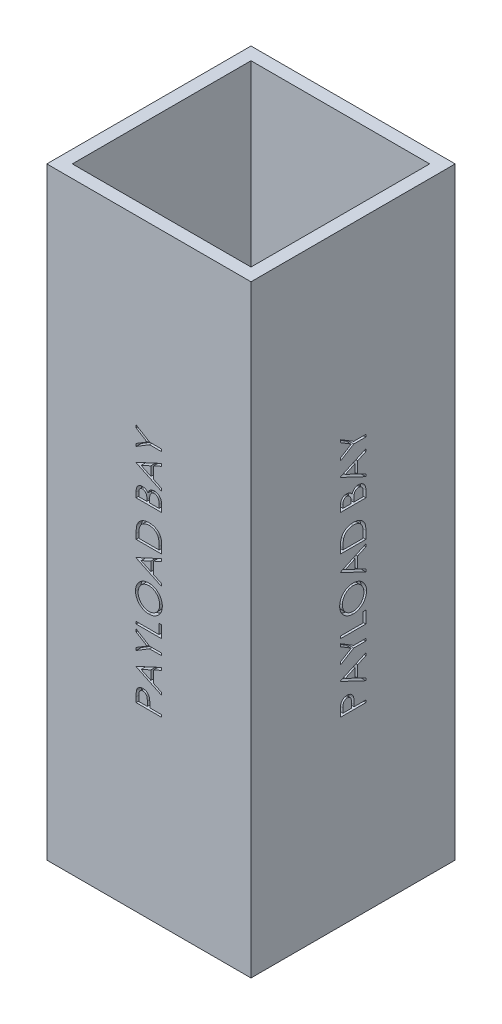
from build123d import *

# Parameters (mm, degrees)
SKETCH1_W           = 101.6
SKETCH1_H           = 101.6
SKETCH1_W_2         = 88.9
SKETCH1_H_2         = 88.9
BOSS_EXTRUDE1_DEPTH = 300
CUT_EXTRUDE1_DEPTH  = 2.54
CIRPATTERN1_COUNT   = 4


with BuildPart() as part:
    # Sketch1 → Boss-Extrude1 (new body)
    with BuildSketch(Plane(origin=(0, 0, 0), x_dir=(1, 0, 0), z_dir=(0, 1, 0))):
        Rectangle(SKETCH1_W, SKETCH1_H)
        Rectangle(SKETCH1_W_2, SKETCH1_H_2, mode=Mode.SUBTRACT)
    extrude(amount=BOSS_EXTRUDE1_DEPTH)

    # Sketch6 → Cut-Extrude1 (cut)
    with BuildSketch(Plane.ZY.offset(50.8)):
        with BuildLine():
            Line((-6.35, 90.082051282), (-6.35, 92.572696314))
            add(Edge.make_bspline(
                [(-6.35, 92.572696314), (-6.349811691, 92.744004459), (-6.349450882, 93.072238473), (-6.338511661, 93.542918818), (-6.323900522, 93.970399844), (-6.303646223, 94.353759798), (-6.279710024, 94.694178211), (-6.246138339, 94.990114698), (-6.211085266, 95.243895374), (-6.175447591, 95.395955919), (-6.159194712, 95.465304487)],
                knots=[0, 0, 0, 0, 0.000513909, 0.000984672, 0.001412348, 0.001797041, 0.002136358, 0.002435846, 0.002690583, 0.002904164, 0.002904164, 0.002904164, 0.002904164], degree=3))
            add(Edge.make_bspline(
                [(-6.159194712, 95.465304487), (-6.135165553, 95.553091687), (-6.087673454, 95.726597491), (-5.99256869, 95.976620926), (-5.879734333, 96.214446609), (-5.751382729, 96.441136022), (-5.601195819, 96.652560376), (-5.439164902, 96.855767619), (-5.254818851, 97.043584549), (-5.053971996, 97.218555122), (-4.839171698, 97.380275569), (-4.60651531, 97.516149986), (-4.36294889, 97.634954344), (-4.105162168, 97.732225501), (-3.832904869, 97.804560375), (-3.548111823, 97.858261731), (-3.250462794, 97.892503698), (-3.047042823, 97.895772087), (-2.943489583, 97.897435897)],
                knots=[0, 0, 0, 0, 0.000272928, 0.000539425, 0.000801167, 0.00106213, 0.001319735, 0.001578393, 0.001841062, 0.00210791, 0.002377077, 0.00264628, 0.002914809, 0.003189345, 0.003471382, 0.003758783, 0.004058271, 0.004368814, 0.004368814, 0.004368814, 0.004368814], degree=3))
            add(Edge.make_bspline(
                [(-2.943489583, 97.897435897), (-2.839067365, 97.895906728), (-2.634758241, 97.892914804), (-2.335862696, 97.857005426), (-2.050227394, 97.808635873), (-1.778485674, 97.734260855), (-1.522251307, 97.636849412), (-1.277608551, 97.522578249), (-1.048719455, 97.384752296), (-0.834753057, 97.226383914), (-0.635508519, 97.050210986), (-0.452429693, 96.856978896), (-0.286588236, 96.647467749), (-0.137612361, 96.422343383), (-0.008956718, 96.179411074), (0.106276931, 95.92235526), (0.20305478, 95.648941618), (0.25396386, 95.459738781), (0.279847756, 95.363541667)],
                knots=[0, 0, 0, 0, 0.000313086, 0.000612574, 0.000902017, 0.001181599, 0.001456135, 0.001723565, 0.001990583, 0.002256192, 0.00252113, 0.002787469, 0.003053674, 0.003321805, 0.003596116, 0.003877417, 0.00416629, 0.004465075, 0.004465075, 0.004465075, 0.004465075], degree=3))
            add(Edge.make_bspline(
                [(0.279847756, 95.363541667), (0.296755106, 95.283975863), (0.333808547, 95.109602778), (0.375455577, 94.822445764), (0.409610691, 94.48794002), (0.441484518, 94.107223684), (0.458373661, 93.679408932), (0.47820427, 93.205476968), (0.487561251, 92.683823846), (0.488152728, 92.319987058), (0.488461538, 92.130028045)],
                knots=[0, 0, 0, 0, 0.000243979, 0.000534694, 0.000869865, 0.001252695, 0.001680583, 0.002154115, 0.002675749, 0.003245626, 0.003245626, 0.003245626, 0.003245626], degree=3))
            Line((0.488461538, 92.130028045), (0.488461538, 91.221794872))
            Line((0.488461538, 91.221794872), (6.35, 91.221794872))
            Line((6.35, 91.221794872), (6.35, 90.082051282))
            Line((6.35, 90.082051282), (-6.35, 90.082051282))
        make_face()
        with BuildLine():
            Line((-5.047435897, 91.221794872), (-0.814102564, 91.221794872))
            Line((-0.814102564, 91.221794872), (-0.786117788, 93.4453125))
            add(Edge.make_bspline(
                [(-0.786117788, 93.4453125), (-0.786058006, 93.553879847), (-0.785942597, 93.763466872), (-0.800452377, 94.066211014), (-0.816979073, 94.347130601), (-0.841974741, 94.605169257), (-0.874740105, 94.84123239), (-0.915487111, 95.053280991), (-0.959785588, 95.244486591), (-1.033797354, 95.464431594), (-1.147598039, 95.711657023), (-1.313260324, 95.981731934), (-1.527867901, 96.208844847), (-1.768488369, 96.40501689), (-2.035447832, 96.563756171), (-2.322580965, 96.675740401), (-2.62563392, 96.744695668), (-2.832880378, 96.75330752), (-2.938401442, 96.757692308)],
                knots=[0, 0, 0, 0, 0.000325651, 0.000628662, 0.000909076, 0.001169816, 0.001406195, 0.001623739, 0.00181749, 0.001994481, 0.002318937, 0.002632302, 0.002940177, 0.003251283, 0.003561503, 0.003867638, 0.004172555, 0.00448885, 0.00448885, 0.00448885, 0.00448885], degree=3))
            add(Edge.make_bspline(
                [(-2.938401442, 96.757692308), (-3.040503948, 96.753110659), (-3.243471094, 96.744002909), (-3.540938354, 96.676309447), (-3.824816581, 96.562553668), (-4.089626181, 96.404878111), (-4.329717186, 96.21346686), (-4.538638533, 95.991169219), (-4.705467251, 95.737416482), (-4.81729303, 95.503335586), (-4.882763075, 95.293719024), (-4.930049703, 95.112545142), (-4.962657093, 94.906933975), (-4.993858298, 94.678839141), (-5.019043897, 94.428550238), (-5.036533738, 94.154476492), (-5.046662216, 93.857530593), (-5.04717176, 93.651390347), (-5.047435897, 93.54453125)],
                knots=[0, 0, 0, 0, 0.000306146, 0.00060858, 0.000909985, 0.001220206, 0.001529716, 0.001828533, 0.002131234, 0.002437391, 0.002603127, 0.00278947, 0.002998595, 0.003227067, 0.003480211, 0.003753009, 0.004050839, 0.004371402, 0.004371402, 0.004371402, 0.004371402], degree=3))
            Line((-5.047435897, 93.54453125), (-5.047435897, 91.221794872))
        make_face(mode=Mode.SUBTRACT)
        Polygon((-6.35, 105.712820513), (6.35, 111.574358974), (6.35, 110.335396635), (2.279487179, 108.457872596), (2.279487179, 102.700641026), (6.35, 100.769691506), (6.35, 99.525641026), (-6.35, 105.55), align=None)
        Polygon((-3.874619391, 105.618689904), (0.976923077, 103.31885016), (0.976923077, 107.857471955), align=None, mode=Mode.SUBTRACT)
        Polygon((-6.35, 112.551282051), (-6.35, 113.856390224), (-0.89296875, 117.194210737), (-6.35, 120.526943109), (-6.35, 121.832051282), (0.312920673, 117.761538462), (6.35, 117.761538462), (6.35, 116.621794872), (0.312920673, 116.621794872), align=None)
        Polygon((-6.35, 123.948717949), (-6.35, 125.088461538), (5.047435897, 125.088461538), (5.047435897, 129.973076923), (6.35, 129.973076923), (6.35, 123.948717949), align=None)
        with BuildLine():
            add(Edge.make_bspline(
                [(-6.675641026, 138.032692308), (-6.669785071, 138.267878789), (-6.658283492, 138.729804442), (-6.567334124, 139.408062537), (-6.41764098, 140.057525074), (-6.206242297, 140.678565423), (-5.932190469, 141.268821615), (-5.599295982, 141.829960687), (-5.205535771, 142.360300963), (-4.756691829, 142.856191897), (-4.26513446, 143.308559312), (-3.738912975, 143.705514067), (-3.184643364, 144.040382863), (-2.60229672, 144.314509446), (-1.99323266, 144.529716981), (-1.354037691, 144.678184212), (-0.688898346, 144.77303121), (-0.235229152, 144.784118924), (-0.005088141, 144.78974359)],
                knots=[0, 0, 0, 0, 0.000705368, 0.001385402, 0.0020488, 0.002702076, 0.003349741, 0.00399766, 0.004656078, 0.005327949, 0.006001364, 0.006657226, 0.007302086, 0.007940532, 0.008585026, 0.009236039, 0.009906328, 0.010596447, 0.010596447, 0.010596447, 0.010596447], degree=3))
            add(Edge.make_bspline(
                [(-0.005088141, 144.78974359), (0.223356266, 144.784117031), (0.673646657, 144.773026431), (1.334584132, 144.678107253), (1.969850898, 144.529054513), (2.578031024, 144.317174008), (3.159194899, 144.042837073), (3.71388411, 143.707475299), (4.241511135, 143.311273919), (4.736454933, 142.860827488), (5.189213913, 142.368333696), (5.588564969, 141.844134632), (5.923579539, 141.2898798), (6.200766497, 140.711312922), (6.411489139, 140.103890905), (6.56490218, 139.472033968), (6.658807614, 138.812299547), (6.669968316, 138.362882653), (6.675641026, 138.134455128)],
                knots=[0, 0, 0, 0, 0.000685036, 0.001350284, 0.001998823, 0.002640075, 0.00327852, 0.003923381, 0.004581277, 0.005254856, 0.005928271, 0.006585666, 0.00722835, 0.007867883, 0.008506734, 0.009153393, 0.009816123, 0.010501158, 0.010501158, 0.010501158, 0.010501158], degree=3))
            add(Edge.make_bspline(
                [(6.675641026, 138.134455128), (6.670018965, 137.904315456), (6.658936386, 137.450648902), (6.563935289, 136.784671659), (6.415376844, 136.145035274), (6.203071175, 135.533568914), (5.928688652, 134.949931598), (5.594118477, 134.392981869), (5.19712685, 133.864955249), (4.746579565, 133.370229483), (4.256099934, 132.917568107), (3.730558494, 132.522926944), (3.180265837, 132.188281533), (2.603694821, 131.914820298), (2.003632729, 131.698323545), (1.376076825, 131.550623205), (0.724604903, 131.455061322), (0.281037815, 131.444049165), (0.055969551, 131.438461538)],
                knots=[0, 0, 0, 0, 0.000690119, 0.001360408, 0.002013897, 0.002657552, 0.003298299, 0.003945339, 0.004603236, 0.005276814, 0.005950229, 0.006602529, 0.007245213, 0.007879059, 0.008513962, 0.009155077, 0.009810248, 0.010485118, 0.010485118, 0.010485118, 0.010485118], degree=3))
            add(Edge.make_bspline(
                [(0.055969551, 131.438461538), (-0.095097562, 131.440401502), (-0.395326011, 131.444256954), (-0.841156245, 131.490672524), (-1.279816632, 131.558024983), (-1.710059786, 131.654551923), (-2.130832502, 131.780795971), (-2.545036699, 131.929756185), (-2.948474782, 132.111692195), (-3.343057946, 132.317361975), (-3.722635205, 132.546911965), (-4.081426835, 132.800461113), (-4.422443595, 133.069103735), (-4.736848437, 133.363610906), (-5.033787705, 133.674276293), (-5.308698135, 134.006139551), (-5.564058671, 134.357175695), (-5.794183909, 134.728895187), (-6.002315626, 135.112138642), (-6.180920628, 135.507205807), (-6.33421348, 135.908731081), (-6.45845876, 136.318595089), (-6.556546433, 136.735709433), (-6.623338831, 137.16098448), (-6.669872784, 137.594081427), (-6.673710006, 137.885859641), (-6.675641026, 138.032692308)],
                knots=[0, 0, 0, 0, 0.000453023, 0.000900331, 0.00134327, 0.001783953, 0.002221843, 0.002660465, 0.003103469, 0.003548398, 0.003994743, 0.004433047, 0.004865726, 0.005295975, 0.005724256, 0.006154227, 0.006587795, 0.007025471, 0.007464852, 0.007895214, 0.008325184, 0.00875333, 0.009179133, 0.00960951, 0.010044159, 0.010484467, 0.010484467, 0.010484467, 0.010484467], degree=3))
        make_face()
        with BuildLine():
            add(Edge.make_bspline(
                [(-5.373076923, 138.088661859), (-5.371612874, 137.968138647), (-5.368698771, 137.728244435), (-5.330103131, 137.371634762), (-5.275488499, 137.019606801), (-5.196168901, 136.672841773), (-5.093572448, 136.330612447), (-4.969833028, 135.992766886), (-4.820275395, 135.660463451), (-4.652079665, 135.334117284), (-4.461036223, 135.021265912), (-4.258166746, 134.721155899), (-4.035933534, 134.441593359), (-3.799142721, 134.178737887), (-3.545739327, 133.933243177), (-3.277387483, 133.705217516), (-2.992926494, 133.494847893), (-2.693527038, 133.304666015), (-2.380860728, 133.135418989), (-2.060904396, 132.983885031), (-1.729897889, 132.858269162), (-1.389906788, 132.758762678), (-1.042429358, 132.674304473), (-0.685572416, 132.621326036), (-0.320566176, 132.582350109), (-0.073887757, 132.579597426), (0.05088141, 132.578205128)],
                knots=[0, 0, 0, 0, 0.000361401, 0.000719348, 0.001074863, 0.001429731, 0.001785501, 0.002146095, 0.002508248, 0.002878058, 0.003246738, 0.003607323, 0.00396412, 0.004317168, 0.004668001, 0.005021764, 0.005372855, 0.005728561, 0.006084895, 0.00643885, 0.006789913, 0.007145683, 0.007501125, 0.007861666, 0.008227207, 0.008601324, 0.008601324, 0.008601324, 0.008601324], degree=3))
            add(Edge.make_bspline(
                [(0.05088141, 132.578205128), (0.234345869, 132.58284164), (0.595277215, 132.591963092), (1.124266852, 132.671486696), (1.63314324, 132.794954947), (2.118873279, 132.973960588), (2.583622971, 133.202317606), (3.025583679, 133.480866807), (3.444625029, 133.812159116), (3.837627676, 134.188256745), (4.19619396, 134.599509589), (4.511375607, 135.035990281), (4.776641272, 135.494245547), (4.998397407, 135.971634123), (5.165459253, 136.47223187), (5.284574271, 136.992829147), (5.361776101, 137.533437463), (5.369274234, 137.901830698), (5.373076923, 138.088661859)],
                knots=[0, 0, 0, 0, 0.000550108, 0.001082232, 0.001601154, 0.002118677, 0.00263181, 0.003152009, 0.003682843, 0.004231661, 0.004781633, 0.005317521, 0.005844193, 0.006367833, 0.006893982, 0.007424089, 0.007968455, 0.008528619, 0.008528619, 0.008528619, 0.008528619], degree=3))
            add(Edge.make_bspline(
                [(5.373076923, 138.088661859), (5.371352914, 138.214245402), (5.367933685, 138.463315285), (5.333446658, 138.833768939), (5.278253288, 139.197582943), (5.198393676, 139.554085094), (5.099767851, 139.903742487), (4.97743268, 140.245500082), (4.830782133, 140.579244366), (4.667344949, 140.906616436), (4.481684714, 141.220286113), (4.281550104, 141.518575726), (4.063238117, 141.797656623), (3.829627504, 142.060388767), (3.57700307, 142.304162974), (3.310282099, 142.5315394), (3.025217373, 142.738271673), (2.727044186, 142.927808831), (2.416657403, 143.099120929), (2.095821442, 143.246271725), (1.766257055, 143.371941549), (1.427722103, 143.473245665), (1.080978091, 143.552668472), (0.725528754, 143.607384366), (0.362093818, 143.645660851), (0.116280345, 143.648545747), (-0.007632212, 143.65)],
                knots=[0, 0, 0, 0, 0.00037666, 0.00074703, 0.001115112, 0.001479909, 0.001842294, 0.002204411, 0.002567866, 0.002935359, 0.003301431, 0.003660587, 0.004012239, 0.004363588, 0.004714421, 0.005064598, 0.005414184, 0.00576989, 0.006123991, 0.006476875, 0.006827938, 0.007181271, 0.007536139, 0.007894167, 0.008259708, 0.008631282, 0.008631282, 0.008631282, 0.008631282], degree=3))
            add(Edge.make_bspline(
                [(-0.007632212, 143.65), (-0.130697041, 143.648544533), (-0.374818801, 143.645657346), (-0.735719484, 143.607403224), (-1.088609709, 143.552608564), (-1.432104078, 143.473641023), (-1.766290161, 143.37185904), (-2.090854054, 143.246356428), (-2.407005009, 143.098364107), (-2.713961172, 142.928516926), (-3.008510573, 142.737597379), (-3.290092515, 142.528972715), (-3.553442649, 142.299057084), (-3.804973342, 142.05435931), (-4.03965346, 141.788996329), (-4.256576238, 141.502921828), (-4.465515493, 141.203258692), (-4.650429047, 140.883230258), (-4.822051388, 140.554134185), (-4.968471586, 140.216134055), (-5.094225799, 139.874057007), (-5.196475173, 139.526535353), (-5.275184667, 139.173733358), (-5.330152005, 138.815856192), (-5.368685515, 138.454153049), (-5.371608475, 138.210878865), (-5.373076923, 138.088661859)],
                knots=[0, 0, 0, 0, 0.000369031, 0.00073204, 0.001087555, 0.001439943, 0.001788407, 0.002134718, 0.002482986, 0.00283486, 0.003186283, 0.003535331, 0.003885231, 0.004234241, 0.004587492, 0.004946738, 0.00531086, 0.005682608, 0.006054677, 0.006423813, 0.006786796, 0.007147444, 0.007509758, 0.007870298, 0.008233308, 0.008599795, 0.008599795, 0.008599795, 0.008599795], degree=3))
        make_face(mode=Mode.SUBTRACT)
        Polygon((-6.35, 152.605128205), (6.35, 158.466666667), (6.35, 157.227704327), (2.279487179, 155.350180288), (2.279487179, 149.592948718), (6.35, 147.661999199), (6.35, 146.417948718), (-6.35, 152.442307692), align=None)
        Polygon((-3.874619391, 152.510997596), (0.976923077, 150.211157853), (0.976923077, 154.749779647), align=None, mode=Mode.SUBTRACT)
        with BuildLine():
            Line((6.35, 160.420512821), (-6.35, 160.420512821))
            Line((-6.35, 160.420512821), (-6.35, 162.984935897))
            add(Edge.make_bspline(
                [(-6.35, 162.984935897), (-6.348394103, 163.207980512), (-6.345291519, 163.638901546), (-6.325619614, 164.26160957), (-6.290819923, 164.837767793), (-6.2401305, 165.365481311), (-6.177889492, 165.846198851), (-6.099873739, 166.278574372), (-6.00775095, 166.664843576), (-5.929208887, 166.902404118), (-5.892067308, 167.01474359)],
                knots=[0, 0, 0, 0, 0.000669134, 0.001292764, 0.001868826, 0.002400433, 0.002882928, 0.003322552, 0.003718071, 0.004072903, 0.004072903, 0.004072903, 0.004072903], degree=3))
            add(Edge.make_bspline(
                [(-5.892067308, 167.01474359), (-5.836093327, 167.161694877), (-5.725414669, 167.452265085), (-5.51631439, 167.865755961), (-5.280367806, 168.256337905), (-5.012145128, 168.620896847), (-4.715148895, 168.96034751), (-4.391500844, 169.278542555), (-4.034011275, 169.56763688), (-3.649043287, 169.832133132), (-3.241529407, 170.070675187), (-2.812137035, 170.27800451), (-2.363076518, 170.450195854), (-1.895588611, 170.593136678), (-1.408647571, 170.705791053), (-0.9016858, 170.782651182), (-0.376707035, 170.833345923), (-0.02047398, 170.838440622), (0.160276442, 170.841025641)],
                knots=[0, 0, 0, 0, 0.000471477, 0.000932263, 0.001387773, 0.001839114, 0.00228809, 0.002739654, 0.00319897, 0.003665423, 0.00413972, 0.004614208, 0.005094222, 0.005581098, 0.006079742, 0.006592118, 0.007118421, 0.007660523, 0.007660523, 0.007660523, 0.007660523], degree=3))
            add(Edge.make_bspline(
                [(0.160276442, 170.841025641), (0.317252935, 170.838743386), (0.626591509, 170.834245964), (1.082488494, 170.793862471), (1.52486052, 170.735165446), (1.951601475, 170.644291121), (2.366448593, 170.533972212), (2.764986355, 170.392592467), (3.150849201, 170.230613026), (3.518898525, 170.041806471), (3.867366737, 169.834246367), (4.196106488, 169.612889743), (4.497822934, 169.372716402), (4.780422415, 169.120834747), (5.036355603, 168.851170688), (5.270287817, 168.567007346), (5.478302523, 168.267240384), (5.663668473, 167.950014161), (5.829436114, 167.61109204), (5.967706215, 167.239813205), (6.087462238, 166.837936329), (6.182728161, 166.40316961), (6.259560811, 165.937063728), (6.310716285, 165.438325694), (6.345409359, 164.907898054), (6.348440074, 164.543663461), (6.35, 164.356189904)],
                knots=[0, 0, 0, 0, 0.000470825, 0.00092781, 0.001372149, 0.001808729, 0.0022358, 0.002659019, 0.003076254, 0.003490407, 0.003898792, 0.004292531, 0.004678333, 0.00505483, 0.005427317, 0.005792478, 0.006158046, 0.006520636, 0.006893843, 0.007288379, 0.00770775, 0.008150915, 0.008622694, 0.009124186, 0.009654385, 0.010216717, 0.010216717, 0.010216717, 0.010216717], degree=3))
            Line((6.35, 164.356189904), (6.35, 160.420512821))
        make_face()
        with BuildLine():
            Line((5.047435897, 161.56025641), (5.047435897, 163.018008814))
            add(Edge.make_bspline(
                [(5.047435897, 163.018008814), (5.046535662, 163.227480331), (5.04480418, 163.630370771), (5.029610614, 164.209701218), (5.004784155, 164.739035028), (4.970040301, 165.218447362), (4.924071326, 165.647667536), (4.872818108, 166.027592571), (4.808964501, 166.35697708), (4.751085305, 166.556292466), (4.724338942, 166.648397436)],
                knots=[0, 0, 0, 0, 0.000628406, 0.001208655, 0.001738433, 0.002218042, 0.002650422, 0.003033235, 0.00336802, 0.003655635, 0.003655635, 0.003655635, 0.003655635], degree=3))
            add(Edge.make_bspline(
                [(4.724338942, 166.648397436), (4.683511867, 166.764324362), (4.602832871, 166.993409301), (4.45566639, 167.323177636), (4.281342714, 167.630725124), (4.087567265, 167.921407724), (3.867514454, 168.191116069), (3.625936061, 168.442993512), (3.36172837, 168.676731682), (3.075319806, 168.888730377), (2.769816125, 169.080752404), (2.444677018, 169.245595261), (2.104473453, 169.389151793), (1.746451287, 169.502822569), (1.373234633, 169.592446996), (0.9828882, 169.655268709), (0.575757403, 169.694269377), (0.298593328, 169.698919006), (0.157732372, 169.701282051)],
                knots=[0, 0, 0, 0, 0.000368636, 0.000728467, 0.00108158, 0.001428031, 0.001775294, 0.002124361, 0.00247402, 0.002832229, 0.003192239, 0.003555195, 0.003924673, 0.00429879, 0.004680748, 0.005075153, 0.005483989, 0.005906496, 0.005906496, 0.005906496, 0.005906496], degree=3))
            add(Edge.make_bspline(
                [(0.157732372, 169.701282051), (0.009202315, 169.699419551), (-0.282586297, 169.695760654), (-0.710723963, 169.649771013), (-1.122496609, 169.582564226), (-1.517931775, 169.485377708), (-1.897800939, 169.361531376), (-2.260003161, 169.206973676), (-2.608363686, 169.030383372), (-2.934842098, 168.820276978), (-3.243608523, 168.590168968), (-3.526473502, 168.334797806), (-3.784081392, 168.058220695), (-4.020444041, 167.763454241), (-4.226052236, 167.442191052), (-4.409972479, 167.101999089), (-4.566058713, 166.737887653), (-4.649076301, 166.4845673), (-4.691266026, 166.355829327)],
                knots=[0, 0, 0, 0, 0.000445394, 0.00087498, 0.001290296, 0.001696304, 0.002095342, 0.002487525, 0.00287666, 0.003265537, 0.003650709, 0.004030799, 0.004406986, 0.004783646, 0.005162584, 0.005549584, 0.005942765, 0.00634906, 0.00634906, 0.00634906, 0.00634906], degree=3))
            add(Edge.make_bspline(
                [(-4.691266026, 166.355829327), (-4.720717064, 166.249326596), (-4.783338052, 166.022872568), (-4.851647261, 165.653340799), (-4.911897871, 165.237451542), (-4.962908471, 164.773358341), (-4.999511037, 164.261590218), (-5.026984093, 163.701753579), (-5.045513874, 163.093606442), (-5.046779183, 162.672029819), (-5.047435897, 162.45322516)],
                knots=[0, 0, 0, 0, 0.000331365, 0.000704572, 0.001126244, 0.001592052, 0.002104832, 0.002665226, 0.00327352, 0.00392991, 0.00392991, 0.00392991, 0.00392991], degree=3))
            Line((-5.047435897, 162.45322516), (-5.047435897, 161.56025641))
            Line((-5.047435897, 161.56025641), (5.047435897, 161.56025641))
        make_face(mode=Mode.SUBTRACT)
        with BuildLine():
            Line((-6.35, 178.330769231), (-6.35, 180.80869391))
            add(Edge.make_bspline(
                [(-6.35, 180.80869391), (-6.349372317, 180.929993444), (-6.34815571, 181.165102129), (-6.32884905, 181.506958107), (-6.303182672, 181.827265278), (-6.260128703, 182.125457622), (-6.215487417, 182.40347543), (-6.149964695, 182.658496238), (-6.077592462, 182.892656163), (-5.966237959, 183.173834305), (-5.793303013, 183.492869434), (-5.536824054, 183.835772502), (-5.229326494, 184.133844772), (-4.878908769, 184.387294554), (-4.493409562, 184.590693397), (-4.081123013, 184.735981885), (-3.64898535, 184.829320743), (-3.352715027, 184.838799389), (-3.202984776, 184.843589744)],
                knots=[0, 0, 0, 0, 0.000363838, 0.000705208, 0.00102698, 0.001327407, 0.001608892, 0.001871129, 0.002116536, 0.002343771, 0.002777466, 0.0032008, 0.003623583, 0.004057151, 0.004494139, 0.004926249, 0.005365321, 0.005813951, 0.005813951, 0.005813951, 0.005813951], degree=3))
            add(Edge.make_bspline(
                [(-3.202984776, 184.843589744), (-3.062737383, 184.839599728), (-2.787138031, 184.83175897), (-2.384737295, 184.757696306), (-2.002077719, 184.640148273), (-1.639486801, 184.47769215), (-1.303714203, 184.268376526), (-0.995800058, 184.017586986), (-0.727381826, 183.716265358), (-0.577377362, 183.490393651), (-0.501181891, 183.375661058)],
                knots=[0, 0, 0, 0, 0.000420396, 0.000826117, 0.001222837, 0.001619092, 0.002014431, 0.002406622, 0.002806568, 0.003219445, 0.003219445, 0.003219445, 0.003219445], degree=3))
            add(Edge.make_bspline(
                [(-0.501181891, 183.375661058), (-0.445773816, 183.519920678), (-0.339764444, 183.795925067), (-0.152634166, 184.17596648), (0.051636421, 184.502202218), (0.271263785, 184.781005131), (0.511490195, 185.018194242), (0.774267381, 185.223613728), (1.059380217, 185.401202875), (1.365780824, 185.552330012), (1.690871704, 185.671042262), (2.030682193, 185.75829412), (2.383909628, 185.809905491), (2.623616838, 185.816946074), (2.745052083, 185.820512821)],
                knots=[0, 0, 0, 0, 0.000463447, 0.000886689, 0.001268545, 0.0016162, 0.001949007, 0.002278795, 0.002614805, 0.002954998, 0.003301897, 0.00365114, 0.00400589, 0.004370127, 0.004370127, 0.004370127, 0.004370127], degree=3))
            add(Edge.make_bspline(
                [(2.745052083, 185.820512821), (2.869029524, 185.81696904), (3.112958611, 185.809996552), (3.471291465, 185.758532445), (3.813764183, 185.671454355), (4.142434121, 185.551303705), (4.456612174, 185.395568463), (4.755160179, 185.203304589), (5.038699261, 184.977211083), (5.307729832, 184.721688874), (5.553901262, 184.436929363), (5.765525674, 184.123106054), (5.947492508, 183.788816177), (6.095643415, 183.429786154), (6.209941742, 183.046932515), (6.289576238, 182.640468299), (6.343323875, 182.211062893), (6.347736865, 181.916385354), (6.35, 181.765264423)],
                knots=[0, 0, 0, 0, 0.000371861, 0.000731647, 0.001083355, 0.001430255, 0.001779543, 0.002133105, 0.002493475, 0.002865962, 0.003244832, 0.003620227, 0.003999302, 0.004384828, 0.004783241, 0.005195859, 0.005626281, 0.006079382, 0.006079382, 0.006079382, 0.006079382], degree=3))
            Line((6.35, 181.765264423), (6.35, 178.330769231))
            Line((6.35, 178.330769231), (-6.35, 178.330769231))
        make_face()
        with BuildLine():
            Line((-5.047435897, 179.470512821), (-0.976923077, 179.470512821))
            Line((-0.976923077, 179.470512821), (-0.976923077, 180.236278045))
            add(Edge.make_bspline(
                [(-0.976923077, 180.236278045), (-0.978374226, 180.348215103), (-0.981178141, 180.564500309), (-0.989210049, 180.877718217), (-1.011700083, 181.168457579), (-1.034183694, 181.43621648), (-1.070739951, 181.680573468), (-1.114254566, 181.900986513), (-1.160274294, 182.100916987), (-1.238545357, 182.331469368), (-1.354184303, 182.593027832), (-1.533820739, 182.871677561), (-1.747610778, 183.118470549), (-1.996602328, 183.324374206), (-2.267797908, 183.494378417), (-2.558816675, 183.613471713), (-2.863802254, 183.692867668), (-3.073579537, 183.700149172), (-3.180088141, 183.703846154)],
                knots=[0, 0, 0, 0, 0.000335856, 0.000648942, 0.000939679, 0.001210548, 0.001454845, 0.001680365, 0.001884605, 0.002069641, 0.0024101, 0.002739663, 0.003060599, 0.003385683, 0.003705519, 0.004016874, 0.004326007, 0.004644839, 0.004644839, 0.004644839, 0.004644839], degree=3))
            add(Edge.make_bspline(
                [(-3.180088141, 183.703846154), (-3.250585181, 183.701969054), (-3.388872822, 183.698286917), (-3.591119209, 183.667034672), (-3.781156629, 183.61639774), (-3.960808966, 183.547821684), (-4.125611427, 183.454136614), (-4.283438701, 183.34554331), (-4.424837705, 183.211469459), (-4.556615938, 183.059954103), (-4.674557016, 182.886593511), (-4.77225292, 182.687652627), (-4.860797869, 182.468274376), (-4.926345062, 182.222506905), (-4.983983541, 181.955442602), (-5.020198184, 181.663465315), (-5.043502651, 181.348425244), (-5.046095572, 181.130142044), (-5.047435897, 181.017307692)],
                knots=[0, 0, 0, 0, 0.000211403, 0.00041469, 0.000612163, 0.000800665, 0.000989698, 0.001179568, 0.001373986, 0.00157239, 0.001781252, 0.00200084, 0.002236108, 0.002489814, 0.002762742, 0.003055266, 0.00337156, 0.003710008, 0.003710008, 0.003710008, 0.003710008], degree=3))
            Line((-5.047435897, 181.017307692), (-5.047435897, 179.470512821))
        make_face(mode=Mode.SUBTRACT)
        with BuildLine():
            Line((0.325641026, 179.470512821), (5.047435897, 179.470512821))
            Line((5.047435897, 179.470512821), (5.047435897, 181.093629808))
            add(Edge.make_bspline(
                [(5.047435897, 181.093629808), (5.045904986, 181.209800616), (5.042954355, 181.433704534), (5.036034513, 181.757237907), (5.009857802, 182.056320822), (4.985709904, 182.33189678), (4.944418036, 182.583234398), (4.905449249, 182.812266982), (4.847602867, 183.015234803), (4.768099821, 183.252754112), (4.640825315, 183.5182458), (4.454878463, 183.808380427), (4.225391341, 184.061373325), (3.964393202, 184.278544111), (3.681391572, 184.457762875), (3.380086158, 184.58636929), (3.066336778, 184.666289903), (2.852362575, 184.675933072), (2.745052083, 184.680769231)],
                knots=[0, 0, 0, 0, 0.000348575, 0.000671832, 0.000970368, 0.00124908, 0.001501302, 0.001734317, 0.001945399, 0.00213366, 0.002485313, 0.002825429, 0.003164106, 0.003505476, 0.003841486, 0.004165184, 0.004484806, 0.004806367, 0.004806367, 0.004806367, 0.004806367], degree=3))
            add(Edge.make_bspline(
                [(2.745052083, 184.680769231), (2.677946231, 184.679770435), (2.54481695, 184.677788953), (2.34920062, 184.647769991), (2.159617461, 184.604342067), (1.975277451, 184.547146241), (1.799280024, 184.467189559), (1.630950229, 184.369169369), (1.466897116, 184.256967846), (1.256812893, 184.083862119), (1.01776619, 183.828402227), (0.786615655, 183.465365211), (0.597190031, 183.054858428), (0.517108985, 182.756426067), (0.475741186, 182.602263622)],
                knots=[0, 0, 0, 0, 0.000201126, 0.000399009, 0.000592174, 0.000784466, 0.000976909, 0.00117066, 0.001368248, 0.001572487, 0.001986491, 0.00241129, 0.002858707, 0.003336803, 0.003336803, 0.003336803, 0.003336803], degree=3))
            add(Edge.make_bspline(
                [(0.475741186, 182.602263622), (0.463204167, 182.540472331), (0.436021324, 182.406496067), (0.407327657, 182.188028561), (0.381764154, 181.938615551), (0.362855097, 181.657681111), (0.343309639, 181.344869802), (0.33570843, 180.999513554), (0.326639687, 180.623022727), (0.325982428, 180.361793261), (0.325641026, 180.226101763)],
                knots=[0, 0, 0, 0, 0.000189102, 0.000410011, 0.000660625, 0.000941212, 0.001254639, 0.001600782, 0.001977382, 0.002384441, 0.002384441, 0.002384441, 0.002384441], degree=3))
            Line((0.325641026, 180.226101763), (0.325641026, 179.470512821))
        make_face(mode=Mode.SUBTRACT)
        Polygon((-6.35, 193.635897436), (6.35, 199.497435897), (6.35, 198.258473558), (2.279487179, 196.380949519), (2.279487179, 190.623717949), (6.35, 188.692768429), (6.35, 187.448717949), (-6.35, 193.473076923), align=None)
        Polygon((-3.874619391, 193.541766827), (0.976923077, 191.241927083), (0.976923077, 195.780548878), align=None, mode=Mode.SUBTRACT)
        Polygon((-6.35, 200.474358974), (-6.35, 201.779467147), (-0.89296875, 205.11728766), (-6.35, 208.450020032), (-6.35, 209.755128205), (0.312920673, 205.684615385), (6.35, 205.684615385), (6.35, 204.544871795), (0.312920673, 204.544871795), align=None)
    cut_extrude1 = extrude(amount=-CUT_EXTRUDE1_DEPTH, mode=Mode.SUBTRACT)

    # CirPattern1: Cut-Extrude1 ×4 about axis
    cirpattern1_axis = Axis((0, 0, 0), (0, 1, 0))
    for i in range(1, CIRPATTERN1_COUNT):
        add(cut_extrude1.rotate(cirpattern1_axis, i * 360 / CIRPATTERN1_COUNT), mode=Mode.SUBTRACT)


solid = part.part
